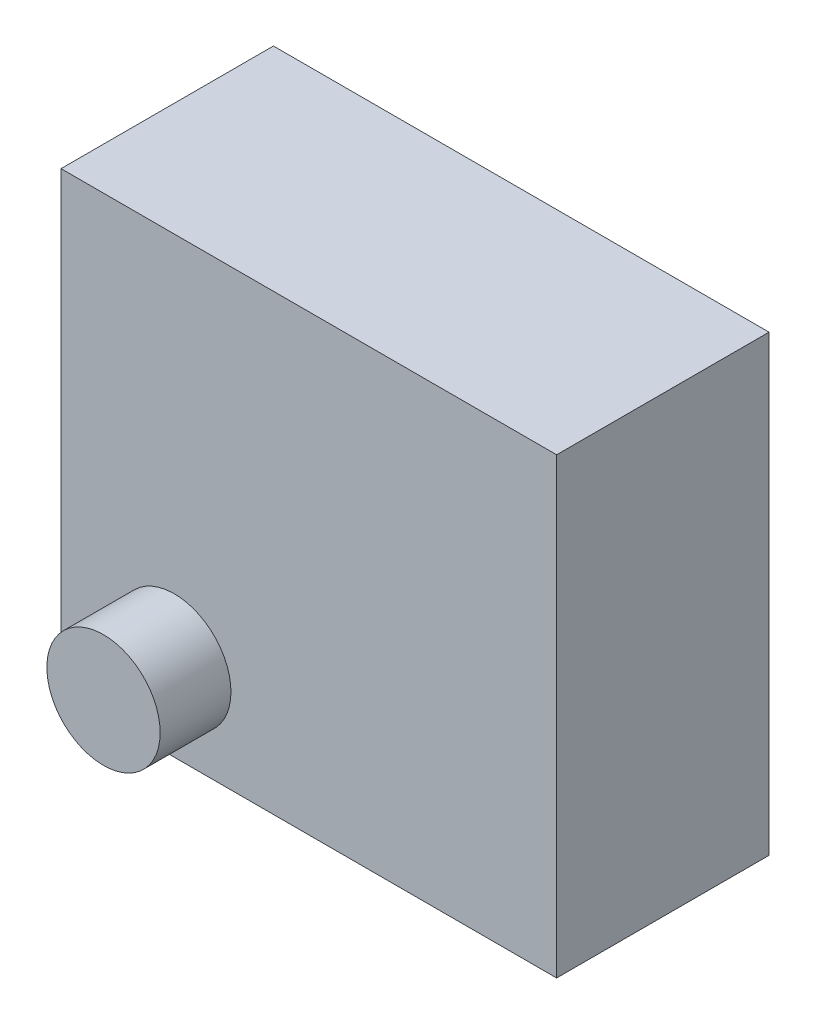
from build123d import *

# Parameters (mm, degrees)
SKETCH_1_W      = 350
SKETCH_1_H      = 320
EXTRUDE_1_DEPTH = 150
SKETCH_2_R      = 40
EXTRUDE_2_DEPTH = 50


with BuildPart() as part:
    # 草图1 → 凸台-拉伸1 (new body)
    with BuildSketch(Plane.XY):
        Rectangle(SKETCH_1_W, SKETCH_1_H)
    extrude(amount=EXTRUDE_1_DEPTH)

    # 草图2 → 凸台-拉伸2 (add)
    with BuildSketch(Plane.XY.offset(150)):
        with Locations((-95, -100)):
            Circle(SKETCH_2_R)
    extrude(amount=EXTRUDE_2_DEPTH)


solid = part.part
